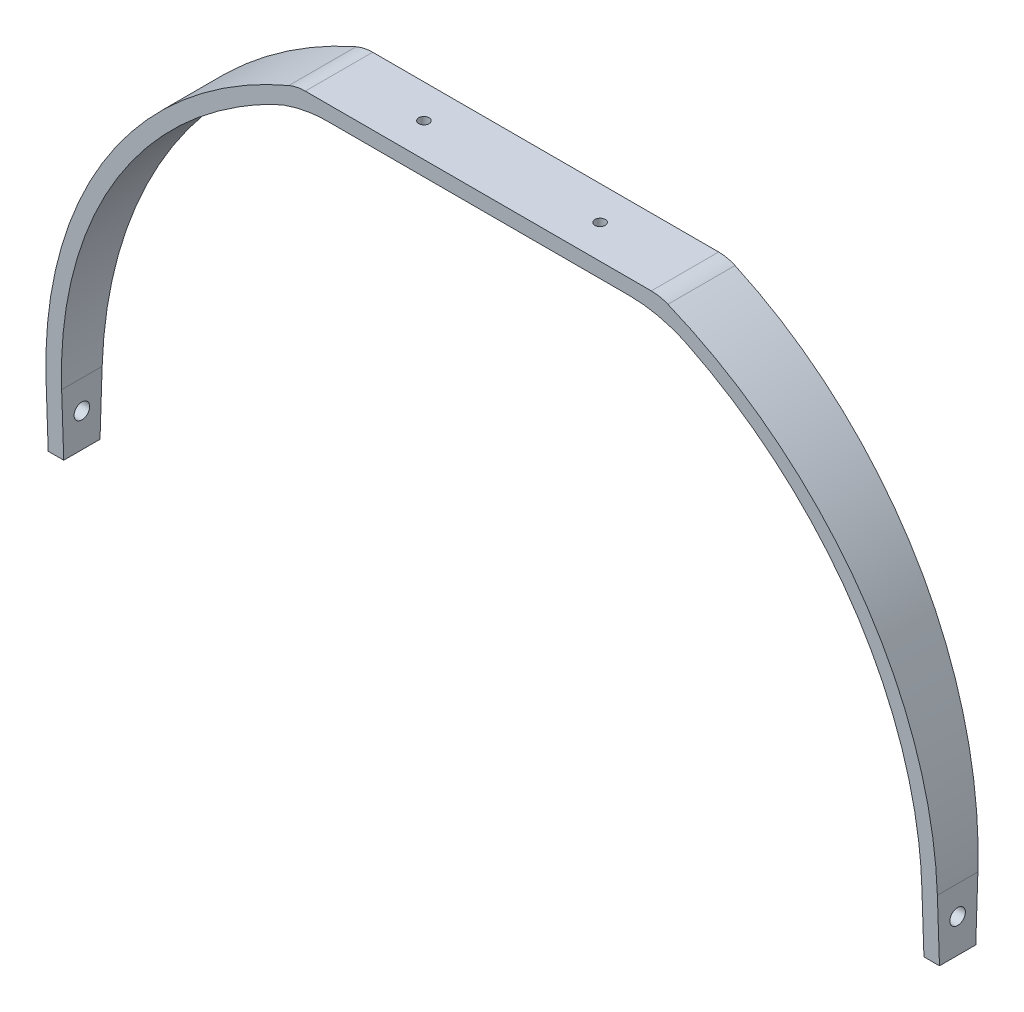
from build123d import *

# Parameters (mm, degrees)
BOSS_EXTRUDE1_DEPTH = 41.275
SKETCH3_R           = 4.7625
CUT_EXTRUDE1_DEPTH  = 547.1
FILLET2_R           = 76.2
FILLET3_R           = 25.4
SKETCH7_R           = 3.175
CUT_EXTRUDE2_DEPTH  = 9.525


with BuildPart() as part:
    # Sketch2 → Boss-Extrude1 (new body)
    with BuildSketch(Plane.XY):
        with BuildLine():
            Line((-273.05, 0), (-273.05, 38.1))
            ThreePointArc((-273.05, 38.1), (-228.817032973, 183.397449758), (-111.125, 279.4))
            Line((-111.125, 279.4), (0, 279.4))
            Line((0, 279.4), (111.125, 279.4))
            ThreePointArc((111.125, 279.4), (228.817032973, 183.397449758), (273.05, 38.1))
            Line((273.05, 38.1), (273.05, 0))
            Line((273.05, 0), (263.525, 0))
            Line((263.525, 0), (263.525, 38.1))
            ThreePointArc((263.525, 38.1), (221.424095798, 177.317474829), (109.231868051, 269.875))
            Line((109.231868051, 269.875), (0, 269.875))
            Line((0, 269.875), (-109.231868051, 269.875))
            ThreePointArc((-109.231868051, 269.875), (-221.424095798, 177.317474829), (-263.525, 38.1))
            Line((-263.525, 38.1), (-263.525, 0))
            Line((-263.525, 0), (-273.05, 0))
        make_face()
    extrude(amount=BOSS_EXTRUDE1_DEPTH)

    # Sketch3 → Cut-Extrude1 (cut, through all)
    with BuildSketch(Plane(origin=(273.05, 0, 0), x_dir=(0, 0, -1), z_dir=(1, 0, 0))):
        with Locations((-20.6375, 20.6375)):
            Circle(SKETCH3_R)
        Polygon((0, 0), (-9.525, 0), (0, 279.4), align=None)
        Polygon((-31.75, 0), (-41.275, 279.4), (-41.275, 0), align=None)
    extrude(amount=-CUT_EXTRUDE1_DEPTH, mode=Mode.SUBTRACT)

    # Fillet2
    fillet2_edges = [part.edges().sort_by_distance(p)[0] for p in [
        (109.231868051, 269.875, 20.6375),
        (-109.231868051, 269.875, 20.6375),
    ]]
    fillet(fillet2_edges, radius=FILLET2_R)

    # Fillet3
    fillet3_edges = [part.edges().sort_by_distance(p)[0] for p in [
        (111.125, 279.4, 20.6375),
        (-111.125, 279.4, 20.6375),
    ]]
    fillet(fillet3_edges, radius=FILLET3_R)

    # Sketch7 → Cut-Extrude2 (cut)
    with BuildSketch(Plane(origin=(0, 279.4, 0), x_dir=(1, 0, 0), z_dir=(0, 1, 0))):
        with Locations((-53.975, -20.6375)):
            Circle(SKETCH7_R)
        with Locations((53.975, -20.6375)):
            Circle(SKETCH7_R)
    extrude(amount=-CUT_EXTRUDE2_DEPTH, mode=Mode.SUBTRACT)


solid = part.part
